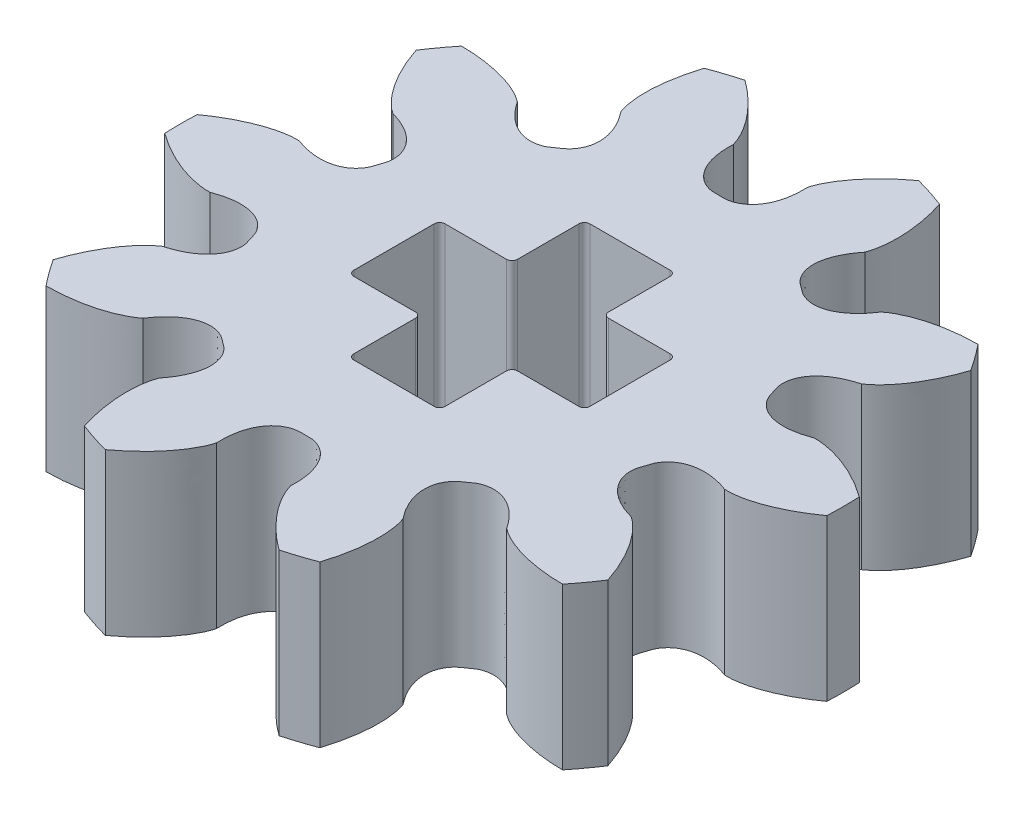
from build123d import *

# Parameters (mm, degrees)
BOSS_EXTRUDE1_DEPTH = 3
FILLET1_R           = 0.1


with BuildPart() as part:
    # Sketch1 → Boss-Extrude1 (new body)
    with BuildSketch(Plane(origin=(0, 0, 0), x_dir=(1, 0, 0), z_dir=(0, 1, 0))):
        with BuildLine():
            ThreePointArc((-2.195246041, -5.776962421), (-1.909725025, -5.877529271), (-1.61962196, -5.963994023))
            add(Edge.make_bspline(
                [(-1.61962196, -5.963994023), (-1.56984541, -5.926389713), (-1.470292055, -5.851180902), (-1.328761717, -5.728585248), (-1.193841186, -5.598826433), (-1.067209813, -5.460903424), (-0.950188009, -5.314730698), (-0.862420789, -5.185625903), (-0.799625352, -5.077784513), (-0.757179661, -4.994397549), (-0.719216402, -4.908719156), (-0.701057464, -4.849011857), (-0.691979526, -4.819163245)],
                knots=[0, 0, 0, 0, 0.010251706, 0.020503464, 0.030755047, 0.041006321, 0.051257106, 0.061507029, 0.066633012, 0.071758798, 0.07688417, 0.082007812, 0.082007812, 0.082007812, 0.082007812], degree=3, weights=[1, 1, 1, 1, 1, 1, 1, 1, 1, 1, 1, 1, 1]))
            add(Edge.make_bspline(
                [(-0.691979526, -4.819163245), (-0.692972091, -4.791041216), (-0.694957195, -4.734797907), (-0.692841973, -4.650377022), (-0.686110642, -4.566172646), (-0.672709266, -4.482813678), (-0.656279018, -4.399951189), (-0.631093663, -4.319279083), (-0.600480092, -4.240553587), (-0.562043943, -4.165226452), (-0.515300654, -4.094752352), (-0.460694656, -4.030167229), (-0.397849492, -3.973436024), (-0.327051342, -3.927084247), (-0.250353587, -3.891173269), (-0.182193787, -3.872913739), (-0.126636908, -3.863689308), (-0.070311712, -3.861657298), (0, -3.863061836), (0.070311712, -3.861657298), (0.126636908, -3.863689308), (0.182193787, -3.872913739), (0.250353587, -3.891173269), (0.327051342, -3.927084247), (0.397849492, -3.973436024), (0.460694656, -4.030167229), (0.515300654, -4.094752352), (0.562043943, -4.165226452), (0.600480092, -4.240553587), (0.631093663, -4.319279083), (0.656279018, -4.399951189), (0.672709266, -4.482813678), (0.686110642, -4.566172646), (0.692841973, -4.650377022), (0.694957195, -4.734797907), (0.692972091, -4.791041216), (0.691979526, -4.819163245)],
                knots=[0, 0, 0, 0, 0.003643402, 0.007286706, 0.010929975, 0.01457286, 0.01821558, 0.021858686, 0.025500936, 0.029144127, 0.032787024, 0.036428762, 0.040069815, 0.043709849, 0.04734977, 0.050988094, 0.052810356, 0.054631699, 0.058275045, 0.061918391, 0.063739733, 0.065561995, 0.069200319, 0.07284024, 0.076480275, 0.080121327, 0.083763065, 0.087405962, 0.091049153, 0.094691403, 0.098334509, 0.101977229, 0.105620114, 0.109263383, 0.112906688, 0.116550089, 0.116550089, 0.116550089, 0.116550089], degree=3, weights=[1, 1, 1, 1, 1, 1, 1, 1, 1, 1, 1, 1, 1, 1, 1, 1, 1, 1, 1, 1, 1, 1, 1, 1, 1, 1, 1, 1, 1, 1, 1, 1, 1, 1, 1, 1, 1]))
            add(Edge.make_bspline(
                [(0.691979526, -4.819163245), (0.701057464, -4.849011857), (0.719216402, -4.908719156), (0.757179661, -4.994397549), (0.799625352, -5.077784513), (0.862420789, -5.185625903), (0.950188009, -5.314730698), (1.067209813, -5.460903424), (1.193841186, -5.598826433), (1.328761717, -5.728585248), (1.470292055, -5.851180902), (1.56984541, -5.926389713), (1.61962196, -5.963994023)],
                knots=[0, 0, 0, 0, 0.002373455, 0.004747711, 0.007122158, 0.009496697, 0.014244829, 0.01899336, 0.023742117, 0.028491018, 0.03324, 0.037988957, 0.037988957, 0.037988957, 0.037988957], degree=3, weights=[1, 1, 1, 1, 1, 1, 1, 1, 1, 1, 1, 1, 1]))
            ThreePointArc((1.61962196, -5.963994023), (1.909725025, -5.877529271), (2.195246041, -5.776962421))
            add(Edge.make_bspline(
                [(2.195246041, -5.776962421), (2.213412858, -5.717281974), (2.249746584, -5.597920774), (2.292187114, -5.415549361), (2.3250698, -5.231267976), (2.346447621, -5.045253864), (2.355202077, -4.858213954), (2.350321355, -4.702177703), (2.337736353, -4.578021954), (2.32306201, -4.485611532), (2.303414436, -4.393982012), (2.283010256, -4.335004236), (2.272809887, -4.305520324)],
                knots=[0, 0, 0, 0, 0.018166013, 0.036332118, 0.054497913, 0.072663161, 0.090827541, 0.108990394, 0.11807363, 0.127156519, 0.136238672, 0.145317761, 0.145317761, 0.145317761, 0.145317761], degree=3, weights=[1, 1, 1, 1, 1, 1, 1, 1, 1, 1, 1, 1, 1]))
            add(Edge.make_bspline(
                [(2.272809887, -4.305520324), (2.255477171, -4.28335254), (2.220812201, -4.239017561), (2.1729021, -4.169476335), (2.128853771, -4.097396987), (2.09069854, -4.022081034), (2.055285541, -3.945386415), (2.028243047, -3.86531773), (2.006736261, -3.78363326), (1.99355558, -3.700100126), (1.989948058, -3.615610366), (1.996163056, -3.531263303), (2.013660096, -3.448427333), (2.043692111, -3.369313849), (2.084633955, -3.295179449), (2.129043709, -3.240343854), (2.168568184, -3.200225618), (2.212941839, -3.165474568), (2.270650776, -3.125282675), (2.326708579, -3.082818193), (2.373471005, -3.051355004), (2.42383945, -3.026162211), (2.489714569, -3.000871156), (2.572872298, -2.984841938), (2.657394096, -2.980727206), (2.741582667, -2.989684254), (2.823722031, -3.009838116), (2.902961782, -3.039377844), (2.978333459, -3.077726575), (3.049374044, -3.123422634), (3.117167299, -3.173884158), (3.179164997, -3.231263862), (3.23900411, -3.290825553), (3.293943962, -3.354991747), (3.345276563, -3.422046381), (3.376729568, -3.468714989), (3.39245628, -3.492049603)],
                knots=[0, 0, 0, 0, 0.008194405, 0.016388591, 0.024582696, 0.03277594, 0.040968812, 0.04916255, 0.057354364, 0.065548295, 0.073741565, 0.081932227, 0.090121349, 0.09830818, 0.106494756, 0.114677741, 0.118776206, 0.122872602, 0.131066881, 0.139261161, 0.143357557, 0.147456021, 0.155639006, 0.163825582, 0.172012413, 0.180201535, 0.188392198, 0.196585467, 0.204779398, 0.212971212, 0.221164951, 0.229357823, 0.237551066, 0.245745171, 0.253939358, 0.262133762, 0.262133762, 0.262133762, 0.262133762], degree=3, weights=[1, 1, 1, 1, 1, 1, 1, 1, 1, 1, 1, 1, 1, 1, 1, 1, 1, 1, 1, 1, 1, 1, 1, 1, 1, 1, 1, 1, 1, 1, 1, 1, 1, 1, 1, 1, 1]))
            add(Edge.make_bspline(
                [(3.39245628, -3.492049603), (3.41734506, -3.51086176), (3.467131019, -3.548492423), (3.548204437, -3.595493456), (3.63155735, -3.638005976), (3.745747504, -3.688341261), (3.892638571, -3.741200956), (4.073229372, -3.790673485), (4.256745415, -3.827823491), (4.442168736, -3.853496278), (4.628729102, -3.869488801), (4.753476088, -3.871818013), (4.815849422, -3.872982616)],
                knots=[0, 0, 0, 0, 0.009079089, 0.018161243, 0.027244131, 0.036327367, 0.05449022, 0.072654601, 0.090819848, 0.108985643, 0.127151749, 0.145317761, 0.145317761, 0.145317761, 0.145317761], degree=3, weights=[1, 1, 1, 1, 1, 1, 1, 1, 1, 1, 1, 1, 1]))
            ThreePointArc((4.815849422, -3.872982616), (4.999725025, -3.632512859), (5.171604669, -3.383327527))
            add(Edge.make_bspline(
                [(5.171604669, -3.383327527), (5.151222645, -3.324366843), (5.110458494, -3.206445175), (5.037598377, -3.033957685), (4.955883148, -2.865542955), (4.863841818, -2.70248881), (4.76098502, -2.546024604), (4.665320626, -2.422657442), (4.582162227, -2.32961061), (4.515972951, -2.26347437), (4.446219249, -2.200893085), (4.395045654, -2.165172339), (4.369463173, -2.147314979)],
                knots=[0, 0, 0, 0, 0.018166013, 0.036332118, 0.054497913, 0.072663161, 0.090827541, 0.108990394, 0.11807363, 0.127156519, 0.136238672, 0.145317761, 0.145317761, 0.145317761, 0.145317761], degree=3, weights=[1, 1, 1, 1, 1, 1, 1, 1, 1, 1, 1, 1, 1]))
            add(Edge.make_bspline(
                [(4.369463173, -2.147314979), (4.342410816, -2.13956878), (4.288306819, -2.124076587), (4.208671426, -2.095977404), (4.130668401, -2.063554944), (4.055530564, -2.02505014), (3.98180088, -1.983818129), (3.912859851, -1.934936381), (3.847447569, -1.881493628), (3.787684629, -1.821661313), (3.735104248, -1.75542811), (3.690554327, -1.683536818), (3.656019968, -1.606236609), (3.63381464, -1.52458008), (3.623362181, -1.440539079), (3.627058872, -1.370072752), (3.635453937, -1.314384514), (3.650926823, -1.260188143), (3.673990132, -1.193751758), (3.69438185, -1.126447319), (3.71371985, -1.073506801), (3.739660825, -1.023519574), (3.778089207, -0.964338258), (3.835943485, -0.902491461), (3.901904477, -0.849481906), (3.975279283, -0.807243509), (4.053577567, -0.77526802), (4.135046889, -0.752590205), (4.218564675, -0.73931262), (4.302897184, -0.734524899), (4.38740362, -0.735501255), (4.471287755, -0.745481078), (4.554708098, -0.75849495), (4.636871315, -0.778113657), (4.717813986, -0.802189449), (4.770691121, -0.821457534), (4.79713004, -0.831091704)],
                knots=[0, 0, 0, 0, 0.008194405, 0.016388591, 0.024582696, 0.03277594, 0.040968812, 0.04916255, 0.057354364, 0.065548295, 0.073741565, 0.081932227, 0.090121349, 0.09830818, 0.106494756, 0.114677741, 0.118776206, 0.122872602, 0.131066881, 0.139261161, 0.143357557, 0.147456021, 0.155639006, 0.163825582, 0.172012413, 0.180201535, 0.188392198, 0.196585467, 0.204779398, 0.212971212, 0.221164951, 0.229357823, 0.237551066, 0.245745171, 0.253939358, 0.262133762, 0.262133762, 0.262133762, 0.262133762], degree=3, weights=[1, 1, 1, 1, 1, 1, 1, 1, 1, 1, 1, 1, 1, 1, 1, 1, 1, 1, 1, 1, 1, 1, 1, 1, 1, 1, 1, 1, 1, 1, 1, 1, 1, 1, 1, 1, 1]))
            add(Edge.make_bspline(
                [(4.79713004, -0.831091704), (4.828322995, -0.831681801), (4.89071943, -0.832862194), (4.983935717, -0.823233069), (5.076357873, -0.808632807), (5.198325986, -0.782235619), (5.348233505, -0.738659608), (5.523413755, -0.672535115), (5.693717578, -0.594722077), (5.858818282, -0.506502705), (6.019148957, -0.409783497), (6.121440465, -0.33834343), (6.172586089, -0.302623488)],
                knots=[0, 0, 0, 0, 0.009079089, 0.018161243, 0.027244131, 0.036327367, 0.05449022, 0.072654601, 0.090819848, 0.108985643, 0.127151749, 0.145317761, 0.145317761, 0.145317761, 0.145317761], degree=3, weights=[1, 1, 1, 1, 1, 1, 1, 1, 1, 1, 1, 1, 1]))
            ThreePointArc((6.172586089, -0.302623488), (6.18, 0), (6.172586089, 0.302623488))
            add(Edge.make_bspline(
                [(6.172586089, 0.302623488), (6.121440465, 0.33834343), (6.019148957, 0.409783497), (5.858818282, 0.506502705), (5.693717578, 0.594722077), (5.523413755, 0.672535115), (5.348233505, 0.738659608), (5.198325986, 0.782235619), (5.076357873, 0.808632807), (4.983935717, 0.823233069), (4.89071943, 0.832862194), (4.828322995, 0.831681801), (4.79713004, 0.831091704)],
                knots=[0, 0, 0, 0, 0.018166013, 0.036332118, 0.054497913, 0.072663161, 0.090827541, 0.108990394, 0.11807363, 0.127156519, 0.136238672, 0.145317761, 0.145317761, 0.145317761, 0.145317761], degree=3, weights=[1, 1, 1, 1, 1, 1, 1, 1, 1, 1, 1, 1, 1]))
            add(Edge.make_bspline(
                [(4.79713004, 0.831091704), (4.770691121, 0.821457534), (4.717813986, 0.802189449), (4.636871315, 0.778113657), (4.554708098, 0.75849495), (4.471287755, 0.745481078), (4.38740362, 0.735501255), (4.302897184, 0.734524899), (4.218564675, 0.73931262), (4.135046889, 0.752590205), (4.053577567, 0.77526802), (3.975279283, 0.807243509), (3.901904477, 0.849481906), (3.835943485, 0.902491461), (3.778089207, 0.964338258), (3.739660825, 1.023519574), (3.71371985, 1.073506801), (3.69438185, 1.126447319), (3.673990132, 1.193751758), (3.650926823, 1.260188143), (3.635453937, 1.314384514), (3.627058872, 1.370072752), (3.623362181, 1.440539079), (3.63381464, 1.52458008), (3.656019968, 1.606236609), (3.690554327, 1.683536818), (3.735104248, 1.75542811), (3.787684629, 1.821661313), (3.847447569, 1.881493628), (3.912859851, 1.934936381), (3.98180088, 1.983818129), (4.055530564, 2.02505014), (4.130668401, 2.063554944), (4.208671426, 2.095977404), (4.288306819, 2.124076587), (4.342410816, 2.13956878), (4.369463173, 2.147314979)],
                knots=[0, 0, 0, 0, 0.008194405, 0.016388591, 0.024582696, 0.03277594, 0.040968812, 0.04916255, 0.057354364, 0.065548295, 0.073741565, 0.081932227, 0.090121349, 0.09830818, 0.106494756, 0.114677741, 0.118776206, 0.122872602, 0.131066881, 0.139261161, 0.143357557, 0.147456021, 0.155639006, 0.163825582, 0.172012413, 0.180201535, 0.188392198, 0.196585467, 0.204779398, 0.212971212, 0.221164951, 0.229357823, 0.237551066, 0.245745171, 0.253939358, 0.262133762, 0.262133762, 0.262133762, 0.262133762], degree=3, weights=[1, 1, 1, 1, 1, 1, 1, 1, 1, 1, 1, 1, 1, 1, 1, 1, 1, 1, 1, 1, 1, 1, 1, 1, 1, 1, 1, 1, 1, 1, 1, 1, 1, 1, 1, 1, 1]))
            add(Edge.make_bspline(
                [(4.369463173, 2.147314979), (4.395045654, 2.165172339), (4.446219249, 2.200893085), (4.515972951, 2.26347437), (4.582162227, 2.32961061), (4.665320626, 2.422657442), (4.76098502, 2.546024604), (4.863841818, 2.70248881), (4.955883148, 2.865542955), (5.037598377, 3.033957685), (5.110458494, 3.206445175), (5.151222645, 3.324366843), (5.171604669, 3.383327527)],
                knots=[0, 0, 0, 0, 0.009079089, 0.018161243, 0.027244131, 0.036327367, 0.05449022, 0.072654601, 0.090819848, 0.108985643, 0.127151749, 0.145317761, 0.145317761, 0.145317761, 0.145317761], degree=3, weights=[1, 1, 1, 1, 1, 1, 1, 1, 1, 1, 1, 1, 1]))
            ThreePointArc((5.171604669, 3.383327527), (4.999725025, 3.632512859), (4.815849422, 3.872982616))
            add(Edge.make_bspline(
                [(4.815849422, 3.872982616), (4.753476088, 3.871818013), (4.628729102, 3.869488801), (4.442168736, 3.853496278), (4.256745415, 3.827823491), (4.073229372, 3.790673485), (3.892638571, 3.741200956), (3.745747504, 3.688341261), (3.63155735, 3.638005976), (3.548204437, 3.595493456), (3.467131019, 3.548492423), (3.41734506, 3.51086176), (3.39245628, 3.492049603)],
                knots=[0, 0, 0, 0, 0.018166013, 0.036332118, 0.054497913, 0.072663161, 0.090827541, 0.108990394, 0.11807363, 0.127156519, 0.136238672, 0.145317761, 0.145317761, 0.145317761, 0.145317761], degree=3, weights=[1, 1, 1, 1, 1, 1, 1, 1, 1, 1, 1, 1, 1]))
            add(Edge.make_bspline(
                [(3.39245628, 3.492049603), (3.376729568, 3.468714989), (3.345276563, 3.422046381), (3.293943962, 3.354991747), (3.23900411, 3.290825553), (3.179164997, 3.231263862), (3.117167299, 3.173884158), (3.049374044, 3.123422634), (2.978333459, 3.077726575), (2.902961782, 3.039377844), (2.823722031, 3.009838116), (2.741582667, 2.989684254), (2.657394096, 2.980727206), (2.572872298, 2.984841938), (2.489714569, 3.000871156), (2.42383945, 3.026162211), (2.373471005, 3.051355004), (2.326708579, 3.082818193), (2.270650776, 3.125282675), (2.212941839, 3.165474568), (2.168568184, 3.200225618), (2.129043709, 3.240343854), (2.084633955, 3.295179449), (2.043692111, 3.369313849), (2.013660096, 3.448427333), (1.996163056, 3.531263303), (1.989948058, 3.615610366), (1.99355558, 3.700100126), (2.006736261, 3.78363326), (2.028243047, 3.86531773), (2.055285541, 3.945386415), (2.09069854, 4.022081034), (2.128853771, 4.097396987), (2.1729021, 4.169476335), (2.220812201, 4.239017561), (2.255477171, 4.28335254), (2.272809887, 4.305520324)],
                knots=[0, 0, 0, 0, 0.008194405, 0.016388591, 0.024582696, 0.03277594, 0.040968812, 0.04916255, 0.057354364, 0.065548295, 0.073741565, 0.081932227, 0.090121349, 0.09830818, 0.106494756, 0.114677741, 0.118776206, 0.122872602, 0.131066881, 0.139261161, 0.143357557, 0.147456021, 0.155639006, 0.163825582, 0.172012413, 0.180201535, 0.188392198, 0.196585467, 0.204779398, 0.212971212, 0.221164951, 0.229357823, 0.237551066, 0.245745171, 0.253939358, 0.262133762, 0.262133762, 0.262133762, 0.262133762], degree=3, weights=[1, 1, 1, 1, 1, 1, 1, 1, 1, 1, 1, 1, 1, 1, 1, 1, 1, 1, 1, 1, 1, 1, 1, 1, 1, 1, 1, 1, 1, 1, 1, 1, 1, 1, 1, 1, 1]))
            add(Edge.make_bspline(
                [(2.272809887, 4.305520324), (2.283010256, 4.335004236), (2.303414436, 4.393982012), (2.32306201, 4.485611532), (2.337736353, 4.578021954), (2.350321355, 4.702177703), (2.355202077, 4.858213954), (2.346447621, 5.045253864), (2.3250698, 5.231267976), (2.292187114, 5.415549361), (2.249746584, 5.597920774), (2.213412858, 5.717281974), (2.195246041, 5.776962421)],
                knots=[0, 0, 0, 0, 0.009079089, 0.018161243, 0.027244131, 0.036327367, 0.05449022, 0.072654601, 0.090819848, 0.108985643, 0.127151749, 0.145317761, 0.145317761, 0.145317761, 0.145317761], degree=3, weights=[1, 1, 1, 1, 1, 1, 1, 1, 1, 1, 1, 1, 1]))
            ThreePointArc((2.195246041, 5.776962421), (1.909725025, 5.877529271), (1.61962196, 5.963994023))
            add(Edge.make_bspline(
                [(1.61962196, 5.963994023), (1.56984541, 5.926389713), (1.470292055, 5.851180902), (1.328761717, 5.728585248), (1.193841186, 5.598826433), (1.067209813, 5.460903424), (0.950188009, 5.314730698), (0.862420789, 5.185625903), (0.799625352, 5.077784513), (0.757179661, 4.994397549), (0.719216402, 4.908719156), (0.701057464, 4.849011857), (0.691979526, 4.819163245)],
                knots=[0, 0, 0, 0, 0.018166013, 0.036332118, 0.054497913, 0.072663161, 0.090827541, 0.108990394, 0.11807363, 0.127156519, 0.136238672, 0.145317761, 0.145317761, 0.145317761, 0.145317761], degree=3, weights=[1, 1, 1, 1, 1, 1, 1, 1, 1, 1, 1, 1, 1]))
            add(Edge.make_bspline(
                [(0.691979526, 4.819163245), (0.692972091, 4.791041216), (0.694957195, 4.734797907), (0.692841973, 4.650377022), (0.686110642, 4.566172646), (0.672709266, 4.482813678), (0.656279018, 4.399951189), (0.631093663, 4.319279083), (0.600480092, 4.240553587), (0.562043943, 4.165226452), (0.515300654, 4.094752352), (0.460694656, 4.030167229), (0.397849492, 3.973436024), (0.327051342, 3.927084247), (0.250353587, 3.891173269), (0.182193787, 3.872913739), (0.126636908, 3.863689308), (0.070311712, 3.861657298), (0, 3.863061836), (-0.070311712, 3.861657298), (-0.126636908, 3.863689308), (-0.182193787, 3.872913739), (-0.250353587, 3.891173269), (-0.327051342, 3.927084247), (-0.397849492, 3.973436024), (-0.460694656, 4.030167229), (-0.515300654, 4.094752352), (-0.562043943, 4.165226452), (-0.600480092, 4.240553587), (-0.631093663, 4.319279083), (-0.656279018, 4.399951189), (-0.672709266, 4.482813678), (-0.686110642, 4.566172646), (-0.692841973, 4.650377022), (-0.694957195, 4.734797907), (-0.692972091, 4.791041216), (-0.691979526, 4.819163245)],
                knots=[0, 0, 0, 0, 0.008194405, 0.016388591, 0.024582696, 0.03277594, 0.040968812, 0.04916255, 0.057354364, 0.065548295, 0.073741565, 0.081932227, 0.090121349, 0.09830818, 0.106494756, 0.114677741, 0.118776206, 0.122872602, 0.131066881, 0.139261161, 0.143357557, 0.147456021, 0.155639006, 0.163825582, 0.172012413, 0.180201535, 0.188392198, 0.196585467, 0.204779398, 0.212971212, 0.221164951, 0.229357823, 0.237551066, 0.245745171, 0.253939358, 0.262133762, 0.262133762, 0.262133762, 0.262133762], degree=3, weights=[1, 1, 1, 1, 1, 1, 1, 1, 1, 1, 1, 1, 1, 1, 1, 1, 1, 1, 1, 1, 1, 1, 1, 1, 1, 1, 1, 1, 1, 1, 1, 1, 1, 1, 1, 1, 1]))
            add(Edge.make_bspline(
                [(-0.691979526, 4.819163245), (-0.701057464, 4.849011857), (-0.719216402, 4.908719156), (-0.757179661, 4.994397549), (-0.799625352, 5.077784513), (-0.862420789, 5.185625903), (-0.950188009, 5.314730698), (-1.067209813, 5.460903424), (-1.193841186, 5.598826433), (-1.328761717, 5.728585248), (-1.470292055, 5.851180902), (-1.56984541, 5.926389713), (-1.61962196, 5.963994023)],
                knots=[0, 0, 0, 0, 0.009079089, 0.018161243, 0.027244131, 0.036327367, 0.05449022, 0.072654601, 0.090819848, 0.108985643, 0.127151749, 0.145317761, 0.145317761, 0.145317761, 0.145317761], degree=3, weights=[1, 1, 1, 1, 1, 1, 1, 1, 1, 1, 1, 1, 1]))
            ThreePointArc((-1.61962196, 5.963994023), (-1.909725025, 5.877529271), (-2.195246041, 5.776962421))
            add(Edge.make_bspline(
                [(-2.195246041, 5.776962421), (-2.213412858, 5.717281974), (-2.249746584, 5.597920774), (-2.292187114, 5.415549361), (-2.3250698, 5.231267976), (-2.346447621, 5.045253864), (-2.355202077, 4.858213954), (-2.350321355, 4.702177703), (-2.337736353, 4.578021954), (-2.32306201, 4.485611532), (-2.303414436, 4.393982012), (-2.283010256, 4.335004236), (-2.272809887, 4.305520324)],
                knots=[0, 0, 0, 0, 0.018166013, 0.036332118, 0.054497913, 0.072663161, 0.090827541, 0.108990394, 0.11807363, 0.127156519, 0.136238672, 0.145317761, 0.145317761, 0.145317761, 0.145317761], degree=3, weights=[1, 1, 1, 1, 1, 1, 1, 1, 1, 1, 1, 1, 1]))
            add(Edge.make_bspline(
                [(-2.272809887, 4.305520324), (-2.255477171, 4.28335254), (-2.220812201, 4.239017561), (-2.1729021, 4.169476335), (-2.128853771, 4.097396987), (-2.09069854, 4.022081034), (-2.055285541, 3.945386415), (-2.028243047, 3.86531773), (-2.006736261, 3.78363326), (-1.99355558, 3.700100126), (-1.989948058, 3.615610366), (-1.996163056, 3.531263303), (-2.013660096, 3.448427333), (-2.043692111, 3.369313849), (-2.084633955, 3.295179449), (-2.129043709, 3.240343854), (-2.168568184, 3.200225618), (-2.212941839, 3.165474568), (-2.270650776, 3.125282675), (-2.326708579, 3.082818193), (-2.373471005, 3.051355004), (-2.42383945, 3.026162211), (-2.489714569, 3.000871156), (-2.572872298, 2.984841938), (-2.657394096, 2.980727206), (-2.741582667, 2.989684254), (-2.823722031, 3.009838116), (-2.902961782, 3.039377844), (-2.978333459, 3.077726575), (-3.049374044, 3.123422634), (-3.117167299, 3.173884158), (-3.179164997, 3.231263862), (-3.23900411, 3.290825553), (-3.293943962, 3.354991747), (-3.345276563, 3.422046381), (-3.376729568, 3.468714989), (-3.39245628, 3.492049603)],
                knots=[0, 0, 0, 0, 0.008194405, 0.016388591, 0.024582696, 0.03277594, 0.040968812, 0.04916255, 0.057354364, 0.065548295, 0.073741565, 0.081932227, 0.090121349, 0.09830818, 0.106494756, 0.114677741, 0.118776206, 0.122872602, 0.131066881, 0.139261161, 0.143357557, 0.147456021, 0.155639006, 0.163825582, 0.172012413, 0.180201535, 0.188392198, 0.196585467, 0.204779398, 0.212971212, 0.221164951, 0.229357823, 0.237551066, 0.245745171, 0.253939358, 0.262133762, 0.262133762, 0.262133762, 0.262133762], degree=3, weights=[1, 1, 1, 1, 1, 1, 1, 1, 1, 1, 1, 1, 1, 1, 1, 1, 1, 1, 1, 1, 1, 1, 1, 1, 1, 1, 1, 1, 1, 1, 1, 1, 1, 1, 1, 1, 1]))
            add(Edge.make_bspline(
                [(-3.39245628, 3.492049603), (-3.41734506, 3.51086176), (-3.467131019, 3.548492423), (-3.548204437, 3.595493456), (-3.63155735, 3.638005976), (-3.745747504, 3.688341261), (-3.892638571, 3.741200956), (-4.073229372, 3.790673485), (-4.256745415, 3.827823491), (-4.442168736, 3.853496278), (-4.628729102, 3.869488801), (-4.753476088, 3.871818013), (-4.815849422, 3.872982616)],
                knots=[0, 0, 0, 0, 0.009079089, 0.018161243, 0.027244131, 0.036327367, 0.05449022, 0.072654601, 0.090819848, 0.108985643, 0.127151749, 0.145317761, 0.145317761, 0.145317761, 0.145317761], degree=3, weights=[1, 1, 1, 1, 1, 1, 1, 1, 1, 1, 1, 1, 1]))
            ThreePointArc((-4.815849422, 3.872982616), (-4.999725025, 3.632512859), (-5.171604669, 3.383327527))
            add(Edge.make_bspline(
                [(-5.171604669, 3.383327527), (-5.151222645, 3.324366843), (-5.110458494, 3.206445175), (-5.037598377, 3.033957685), (-4.955883148, 2.865542955), (-4.863841818, 2.70248881), (-4.76098502, 2.546024604), (-4.665320626, 2.422657442), (-4.582162227, 2.32961061), (-4.515972951, 2.26347437), (-4.446219249, 2.200893085), (-4.395045654, 2.165172339), (-4.369463173, 2.147314979)],
                knots=[0, 0, 0, 0, 0.018166013, 0.036332118, 0.054497913, 0.072663161, 0.090827541, 0.108990394, 0.11807363, 0.127156519, 0.136238672, 0.145317761, 0.145317761, 0.145317761, 0.145317761], degree=3, weights=[1, 1, 1, 1, 1, 1, 1, 1, 1, 1, 1, 1, 1]))
            add(Edge.make_bspline(
                [(-4.369463173, 2.147314979), (-4.342410816, 2.13956878), (-4.288306819, 2.124076587), (-4.208671426, 2.095977404), (-4.130668401, 2.063554944), (-4.055530564, 2.02505014), (-3.98180088, 1.983818129), (-3.912859851, 1.934936381), (-3.847447569, 1.881493628), (-3.787684629, 1.821661313), (-3.735104248, 1.75542811), (-3.690554327, 1.683536818), (-3.656019968, 1.606236609), (-3.63381464, 1.52458008), (-3.623362181, 1.440539079), (-3.627058872, 1.370072752), (-3.635453937, 1.314384514), (-3.650926823, 1.260188143), (-3.673990132, 1.193751758), (-3.69438185, 1.126447319), (-3.71371985, 1.073506801), (-3.739660825, 1.023519574), (-3.778089207, 0.964338258), (-3.835943485, 0.902491461), (-3.901904477, 0.849481906), (-3.975279283, 0.807243509), (-4.053577567, 0.77526802), (-4.135046889, 0.752590205), (-4.218564675, 0.73931262), (-4.302897184, 0.734524899), (-4.38740362, 0.735501255), (-4.471287755, 0.745481078), (-4.554708098, 0.75849495), (-4.636871315, 0.778113657), (-4.717813986, 0.802189449), (-4.770691121, 0.821457534), (-4.79713004, 0.831091704)],
                knots=[0, 0, 0, 0, 0.008194405, 0.016388591, 0.024582696, 0.03277594, 0.040968812, 0.04916255, 0.057354364, 0.065548295, 0.073741565, 0.081932227, 0.090121349, 0.09830818, 0.106494756, 0.114677741, 0.118776206, 0.122872602, 0.131066881, 0.139261161, 0.143357557, 0.147456021, 0.155639006, 0.163825582, 0.172012413, 0.180201535, 0.188392198, 0.196585467, 0.204779398, 0.212971212, 0.221164951, 0.229357823, 0.237551066, 0.245745171, 0.253939358, 0.262133762, 0.262133762, 0.262133762, 0.262133762], degree=3, weights=[1, 1, 1, 1, 1, 1, 1, 1, 1, 1, 1, 1, 1, 1, 1, 1, 1, 1, 1, 1, 1, 1, 1, 1, 1, 1, 1, 1, 1, 1, 1, 1, 1, 1, 1, 1, 1]))
            add(Edge.make_bspline(
                [(-4.79713004, 0.831091704), (-4.828322995, 0.831681801), (-4.89071943, 0.832862194), (-4.983935717, 0.823233069), (-5.076357873, 0.808632807), (-5.198325986, 0.782235619), (-5.348233505, 0.738659608), (-5.523413755, 0.672535115), (-5.693717578, 0.594722077), (-5.858818282, 0.506502705), (-6.019148957, 0.409783497), (-6.121440465, 0.33834343), (-6.172586089, 0.302623488)],
                knots=[0, 0, 0, 0, 0.009079089, 0.018161243, 0.027244131, 0.036327367, 0.05449022, 0.072654601, 0.090819848, 0.108985643, 0.127151749, 0.145317761, 0.145317761, 0.145317761, 0.145317761], degree=3, weights=[1, 1, 1, 1, 1, 1, 1, 1, 1, 1, 1, 1, 1]))
            ThreePointArc((-6.172586089, 0.302623488), (-6.18, 0), (-6.172586089, -0.302623488))
            add(Edge.make_bspline(
                [(-6.172586089, -0.302623488), (-6.121440465, -0.33834343), (-6.019148957, -0.409783497), (-5.858818282, -0.506502705), (-5.693717578, -0.594722077), (-5.523413755, -0.672535115), (-5.348233505, -0.738659608), (-5.198325986, -0.782235619), (-5.076357873, -0.808632807), (-4.983935717, -0.823233069), (-4.89071943, -0.832862194), (-4.828322995, -0.831681801), (-4.79713004, -0.831091704)],
                knots=[0, 0, 0, 0, 0.018166013, 0.036332118, 0.054497913, 0.072663161, 0.090827541, 0.108990394, 0.11807363, 0.127156519, 0.136238672, 0.145317761, 0.145317761, 0.145317761, 0.145317761], degree=3, weights=[1, 1, 1, 1, 1, 1, 1, 1, 1, 1, 1, 1, 1]))
            add(Edge.make_bspline(
                [(-4.79713004, -0.831091704), (-4.770691121, -0.821457534), (-4.717813986, -0.802189449), (-4.636871315, -0.778113657), (-4.554708098, -0.75849495), (-4.471287755, -0.745481078), (-4.38740362, -0.735501255), (-4.302897184, -0.734524899), (-4.218564675, -0.73931262), (-4.135046889, -0.752590205), (-4.053577567, -0.77526802), (-3.975279283, -0.807243509), (-3.901904477, -0.849481906), (-3.835943485, -0.902491461), (-3.778089207, -0.964338258), (-3.739660825, -1.023519574), (-3.71371985, -1.073506801), (-3.69438185, -1.126447319), (-3.673990132, -1.193751758), (-3.650926823, -1.260188143), (-3.635453937, -1.314384514), (-3.627058872, -1.370072752), (-3.623362181, -1.440539079), (-3.63381464, -1.52458008), (-3.656019968, -1.606236609), (-3.690554327, -1.683536818), (-3.735104248, -1.75542811), (-3.787684629, -1.821661313), (-3.847447569, -1.881493628), (-3.912859851, -1.934936381), (-3.98180088, -1.983818129), (-4.055530564, -2.02505014), (-4.130668401, -2.063554944), (-4.208671426, -2.095977404), (-4.288306819, -2.124076587), (-4.342410816, -2.13956878), (-4.369463173, -2.147314979)],
                knots=[0, 0, 0, 0, 0.008194405, 0.016388591, 0.024582696, 0.03277594, 0.040968812, 0.04916255, 0.057354364, 0.065548295, 0.073741565, 0.081932227, 0.090121349, 0.09830818, 0.106494756, 0.114677741, 0.118776206, 0.122872602, 0.131066881, 0.139261161, 0.143357557, 0.147456021, 0.155639006, 0.163825582, 0.172012413, 0.180201535, 0.188392198, 0.196585467, 0.204779398, 0.212971212, 0.221164951, 0.229357823, 0.237551066, 0.245745171, 0.253939358, 0.262133762, 0.262133762, 0.262133762, 0.262133762], degree=3, weights=[1, 1, 1, 1, 1, 1, 1, 1, 1, 1, 1, 1, 1, 1, 1, 1, 1, 1, 1, 1, 1, 1, 1, 1, 1, 1, 1, 1, 1, 1, 1, 1, 1, 1, 1, 1, 1]))
            add(Edge.make_bspline(
                [(-4.369463173, -2.147314979), (-4.395045654, -2.165172339), (-4.446219249, -2.200893085), (-4.515972951, -2.26347437), (-4.582162227, -2.32961061), (-4.665320626, -2.422657442), (-4.76098502, -2.546024604), (-4.863841818, -2.70248881), (-4.955883148, -2.865542955), (-5.037598377, -3.033957685), (-5.110458494, -3.206445175), (-5.151222645, -3.324366843), (-5.171604669, -3.383327527)],
                knots=[0, 0, 0, 0, 0.009079089, 0.018161243, 0.027244131, 0.036327367, 0.05449022, 0.072654601, 0.090819848, 0.108985643, 0.127151749, 0.145317761, 0.145317761, 0.145317761, 0.145317761], degree=3, weights=[1, 1, 1, 1, 1, 1, 1, 1, 1, 1, 1, 1, 1]))
            ThreePointArc((-5.171604669, -3.383327527), (-4.999725025, -3.632512859), (-4.815849422, -3.872982616))
            add(Edge.make_bspline(
                [(-4.815849422, -3.872982616), (-4.753476088, -3.871818013), (-4.628729102, -3.869488801), (-4.442168736, -3.853496278), (-4.256745415, -3.827823491), (-4.073229372, -3.790673485), (-3.892638571, -3.741200956), (-3.745747504, -3.688341261), (-3.63155735, -3.638005976), (-3.548204437, -3.595493456), (-3.467131019, -3.548492423), (-3.41734506, -3.51086176), (-3.39245628, -3.492049603)],
                knots=[0, 0, 0, 0, 0.018166013, 0.036332118, 0.054497913, 0.072663161, 0.090827541, 0.108990394, 0.11807363, 0.127156519, 0.136238672, 0.145317761, 0.145317761, 0.145317761, 0.145317761], degree=3, weights=[1, 1, 1, 1, 1, 1, 1, 1, 1, 1, 1, 1, 1]))
            add(Edge.make_bspline(
                [(-3.39245628, -3.492049603), (-3.376729568, -3.468714989), (-3.345276563, -3.422046381), (-3.293943962, -3.354991747), (-3.23900411, -3.290825553), (-3.179164997, -3.231263862), (-3.117167299, -3.173884158), (-3.049374044, -3.123422634), (-2.978333459, -3.077726575), (-2.902961782, -3.039377844), (-2.823722031, -3.009838116), (-2.741582667, -2.989684254), (-2.657394096, -2.980727206), (-2.572872298, -2.984841938), (-2.489714569, -3.000871156), (-2.42383945, -3.026162211), (-2.373471005, -3.051355004), (-2.326708579, -3.082818193), (-2.270650776, -3.125282675), (-2.212941839, -3.165474568), (-2.168568184, -3.200225618), (-2.129043709, -3.240343854), (-2.084633955, -3.295179449), (-2.043692111, -3.369313849), (-2.013660096, -3.448427333), (-1.996163056, -3.531263303), (-1.989948058, -3.615610366), (-1.99355558, -3.700100126), (-2.006736261, -3.78363326), (-2.028243047, -3.86531773), (-2.055285541, -3.945386415), (-2.09069854, -4.022081034), (-2.128853771, -4.097396987), (-2.1729021, -4.169476335), (-2.220812201, -4.239017561), (-2.255477171, -4.28335254), (-2.272809887, -4.305520324)],
                knots=[0, 0, 0, 0, 0.008194405, 0.016388591, 0.024582696, 0.03277594, 0.040968812, 0.04916255, 0.057354364, 0.065548295, 0.073741565, 0.081932227, 0.090121349, 0.09830818, 0.106494756, 0.114677741, 0.118776206, 0.122872602, 0.131066881, 0.139261161, 0.143357557, 0.147456021, 0.155639006, 0.163825582, 0.172012413, 0.180201535, 0.188392198, 0.196585467, 0.204779398, 0.212971212, 0.221164951, 0.229357823, 0.237551066, 0.245745171, 0.253939358, 0.262133762, 0.262133762, 0.262133762, 0.262133762], degree=3, weights=[1, 1, 1, 1, 1, 1, 1, 1, 1, 1, 1, 1, 1, 1, 1, 1, 1, 1, 1, 1, 1, 1, 1, 1, 1, 1, 1, 1, 1, 1, 1, 1, 1, 1, 1, 1, 1]))
            add(Edge.make_bspline(
                [(-2.272809887, -4.305520324), (-2.283010256, -4.335004236), (-2.303414436, -4.393982012), (-2.32306201, -4.485611532), (-2.337736353, -4.578021954), (-2.350321355, -4.702177703), (-2.355202077, -4.858213954), (-2.346447621, -5.045253864), (-2.3250698, -5.231267976), (-2.292187114, -5.415549361), (-2.249746584, -5.597920774), (-2.213412858, -5.717281974), (-2.195246041, -5.776962421)],
                knots=[0, 0, 0, 0, 0.009079089, 0.018161243, 0.027244131, 0.036327367, 0.05449022, 0.072654601, 0.090819848, 0.108985643, 0.127151749, 0.145317761, 0.145317761, 0.145317761, 0.145317761], degree=3, weights=[1, 1, 1, 1, 1, 1, 1, 1, 1, 1, 1, 1, 1]))
        make_face()
        Polygon((-2.2, 0.85), (-2.2, -0.85), (-0.85, -0.85), (-0.85, -2.2), (0.85, -2.2), (0.85, -0.85), (2.2, -0.85), (2.2, 0.85), (0.85, 0.85), (0.85, 2.2), (-0.85, 2.2), (-0.85, 0.85), align=None, mode=Mode.SUBTRACT)
    extrude(amount=BOSS_EXTRUDE1_DEPTH)

    # Fillet1
    fillet1_edges = [part.edges().sort_by_distance(p)[0] for p in [
        (-0.85, 1.5, -0.85),
        (-2.2, 1.5, -0.85),
        (-2.2, 1.5, 0.85),
        (-0.85, 1.5, 0.85),
        (-0.85, 1.5, 2.2),
        (0.85, 1.5, 2.2),
        (0.85, 1.5, 0.85),
        (2.2, 1.5, 0.85),
        (2.2, 1.5, -0.85),
        (0.85, 1.5, -0.85),
        (0.85, 1.5, -2.2),
        (-0.85, 1.5, -2.2),
    ]]
    fillet(fillet1_edges, radius=FILLET1_R)


solid = part.part
